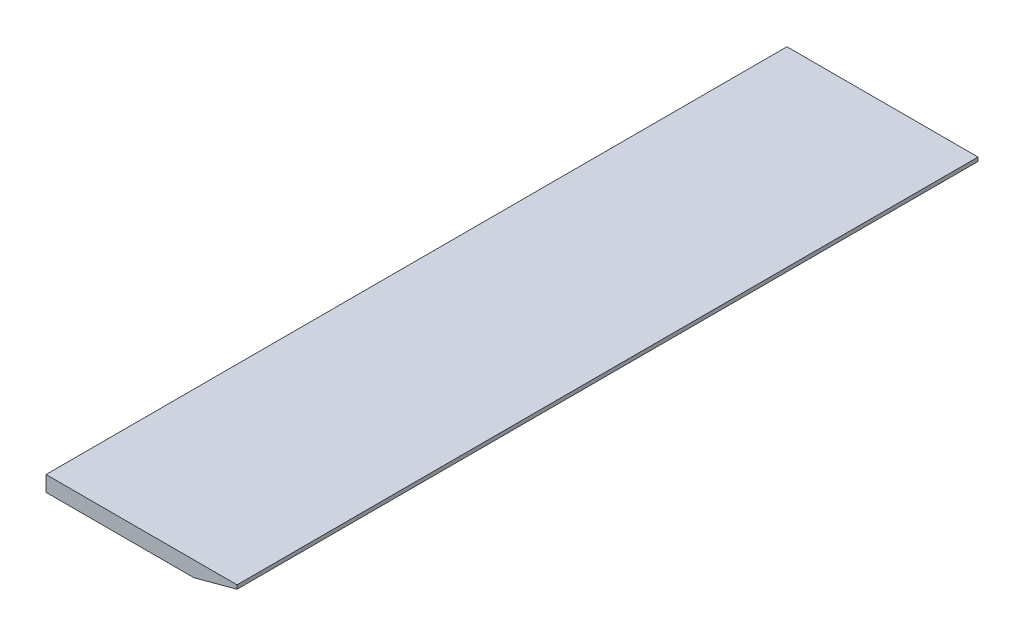
from build123d import *

# Parameters (mm, degrees)
BOSS_EXTRUDE1_DEPTH = 304.8


with BuildPart() as part:
    # Sketch1 → Boss-Extrude1 (new body, symmetric)
    with BuildSketch(Plane.XY):
        Polygon((0, 0), (0, 12.7), (157.1752, 12.7), (157.1752, 9.525), (121.627416058, 0), align=None)
    extrude(amount=BOSS_EXTRUDE1_DEPTH, both=True)


solid = part.part
